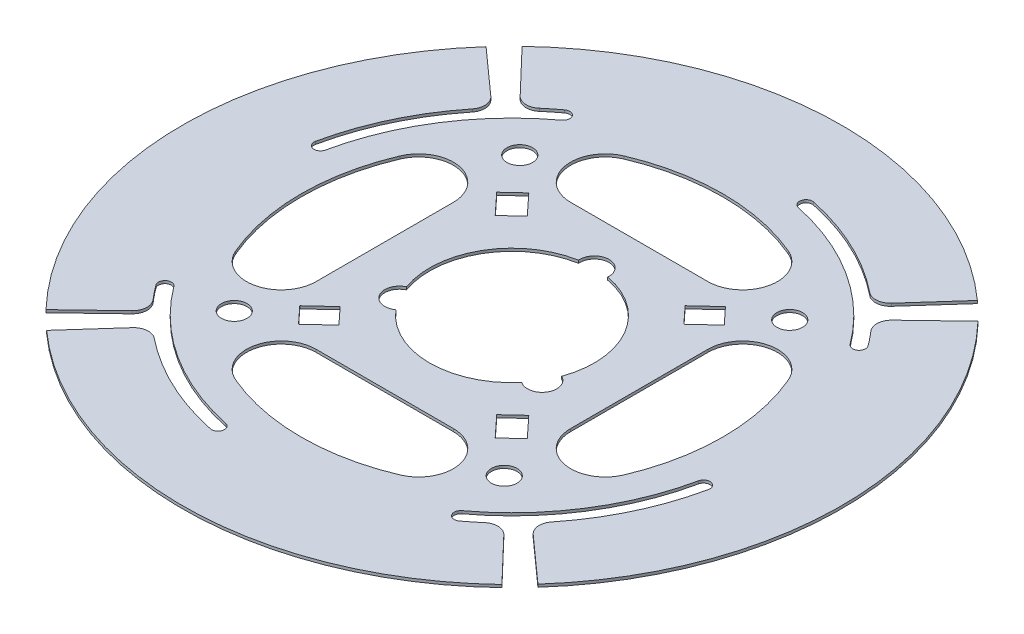
from build123d import *

# Parameters (mm, degrees)
SKETCH2_R                = 90
BOSS_EXTRUDE1_DEPTH      = 0.75
CUT_EXTRUDE2_DEPTH       = 0.75
CUT_EXTRUDE6_START       = -1.75
CUT_EXTRUDE6_DEPTH       = 2.5
CUT_EXTRUDE7_DEPTH       = 0.75
FILLET1_R                = 4
CIRPATTERN1_COUNT        = 4
CIRPATTERN2_COUNT        = 4
FILLET1_OF_CIRPATTERN2_R = 4
SKETCH9_R                = 3.5
CUT_EXTRUDE8_DEPTH       = 0.75
CIRPATTERN3_COUNT        = 4


with BuildPart() as part:
    # Sketch2 → Boss-Extrude1 (new body)
    with BuildSketch(Plane(origin=(0, 0, 0), x_dir=(1, 0, 0), z_dir=(0, 1, 0))):
        Circle(SKETCH2_R)
        with BuildLine():
            ThreePointArc((21.169734538, -7.621833087), (22.857266397, -9.097867547), (23.485571585, -11.25))
            ThreePointArc((23.485571585, -11.25), (21.32947872, -14.799648783), (17.185568345, -14.522611358))
            ThreePointArc((17.185568345, -14.522611358), (0, -22.5), (-17.185568345, -14.522611358))
            ThreePointArc((-17.185568345, -14.522611358), (-22.9496732, -13.25), (-21.169734538, -7.621833087))
            ThreePointArc((-21.169734538, -7.621833087), (-19.485571585, 11.25), (-3.984166192, 22.144444444))
            ThreePointArc((-3.984166192, 22.144444444), (-0.177953971, 26.496039587), (4, 22.5))
            ThreePointArc((4, 22.5), (3.996039587, 22.322046029), (3.984166192, 22.144444444))
            ThreePointArc((3.984166192, 22.144444444), (17.261137554, 14.432710429), (22.5, 0))
            ThreePointArc((22.5, 0), (22.164938835, -3.8685251), (21.169734538, -7.621833087))
        make_face(mode=Mode.SUBTRACT)
    extrude(amount=BOSS_EXTRUDE1_DEPTH)

    # Sketch4 → Cut-Extrude2 (cut)
    with BuildSketch(Plane(origin=(0, 0.75, 0), x_dir=(1, 0, 0), z_dir=(0, 1, 0))):
        with BuildLine():
            Line((-18.75, 34.75), (18.75, 34.75))
            ThreePointArc((18.75, 34.75), (28.059393859, 42.356541264), (22.4609375, 52.995224003))
            ThreePointArc((22.4609375, 52.995224003), (0, 57.563605035), (-22.4609375, 52.995224003))
            ThreePointArc((-22.4609375, 52.995224003), (-28.059393859, 42.356541264), (-18.75, 34.75))
        make_face()
    cut_extrude2 = extrude(amount=-CUT_EXTRUDE2_DEPTH, mode=Mode.SUBTRACT)

    # Sketch7 → Cut-Extrude6 (cut)
    with BuildSketch(Plane(origin=(0, 0.75, 0), x_dir=(1, 0, 0), z_dir=(0, 1, 0)).offset(CUT_EXTRUDE6_START)):
        with BuildLine():
            Line((50.187203194, 48.078005736), (65, 62.24949799))
            ThreePointArc((65, 62.24949799), (62.546689472, 64.714076027), (60, 67.082039325))
            Line((60, 67.082039325), (46.326130039, 51.8086834))
            ThreePointArc((46.326130039, 51.8086834), (31.405257095, 61.999676022), (14.361623616, 67.99995417))
            ThreePointArc((14.361623616, 67.99995417), (12.287770938, 66.649348724), (13.638376384, 64.575496046))
            ThreePointArc((13.638376384, 64.575496046), (35.62942383, 55.556675185), (52.99956323, 39.332509421))
            ThreePointArc((52.99956323, 39.332509421), (55.447762126, 38.970125419), (55.810146129, 41.418324315))
            ThreePointArc((55.810146129, 41.418324315), (53.103176506, 44.836398662), (50.187203194, 48.078005736))
        make_face()
    cut_extrude6 = extrude(amount=CUT_EXTRUDE6_DEPTH, mode=Mode.SUBTRACT)

    # Sketch8 → Cut-Extrude7 (cut)
    with BuildSketch(Plane(origin=(0, 0.75, 0), x_dir=(1, 0, 0), z_dir=(0, 1, 0))):
        Polygon((-25.925493975, 21.336832502), (-31.229304965, 27.056062257), (-26.683250545, 31.271912018), (-21.379439555, 25.552682263), align=None)
    cut_extrude7 = extrude(amount=-CUT_EXTRUDE7_DEPTH, mode=Mode.SUBTRACT)

    # Fillet1
    fillet1_edges = [part.edges().sort_by_distance(p)[0] for p in [
        (50.187203194, 0.375, -48.078005736),
        (46.326130039, 0.375, -51.8086834),
    ]]
    fillet(fillet1_edges, radius=FILLET1_R)

    # CirPattern1: Cut-Extrude2, Cut-Extrude7 ×4 about axis
    cirpattern1_axis = Axis((0, 0, 0), (0, 1, 0))
    for i in range(1, CIRPATTERN1_COUNT):
        add(cut_extrude2.rotate(cirpattern1_axis, i * 360 / CIRPATTERN1_COUNT), mode=Mode.SUBTRACT)
        add(cut_extrude7.rotate(cirpattern1_axis, i * 360 / CIRPATTERN1_COUNT), mode=Mode.SUBTRACT)

    # CirPattern2: Cut-Extrude6 ×4 about axis
    cirpattern2_axis = Axis((0, 0, 0), (0, 1, 0))
    for i in range(1, CIRPATTERN2_COUNT):
        add(cut_extrude6.rotate(cirpattern2_axis, i * 360 / CIRPATTERN2_COUNT), mode=Mode.SUBTRACT)

    # Fillet1 of CirPattern2
    fillet1_of_cirpattern2_edges = [part.edges().sort_by_distance(p)[0] for p in [
        (-48.078005736, 0.375, -50.187203194),
        (-51.8086834, 0.375, -46.326130039),
        (-50.187203194, 0.375, 48.078005736),
        (-46.326130039, 0.375, 51.8086834),
        (48.078005736, 0.375, 50.187203194),
        (51.8086834, 0.375, 46.326130039),
    ]]
    fillet(fillet1_of_cirpattern2_edges, radius=FILLET1_OF_CIRPATTERN2_R)

    # Sketch9 → Cut-Extrude8 (cut)
    with BuildSketch(Plane(origin=(0, 0.75, 0), x_dir=(1, 0, 0), z_dir=(0, 1, 0))):
        with Locations((-36.860788245, 38.982108588)):
            Circle(SKETCH9_R)
    cut_extrude8 = extrude(amount=-CUT_EXTRUDE8_DEPTH, mode=Mode.SUBTRACT)

    # CirPattern3: Cut-Extrude8 ×4 about axis
    cirpattern3_axis = Axis((0, 0, 0), (0, 1, 0))
    for i in range(1, CIRPATTERN3_COUNT):
        add(cut_extrude8.rotate(cirpattern3_axis, i * 360 / CIRPATTERN3_COUNT), mode=Mode.SUBTRACT)


solid = part.part
